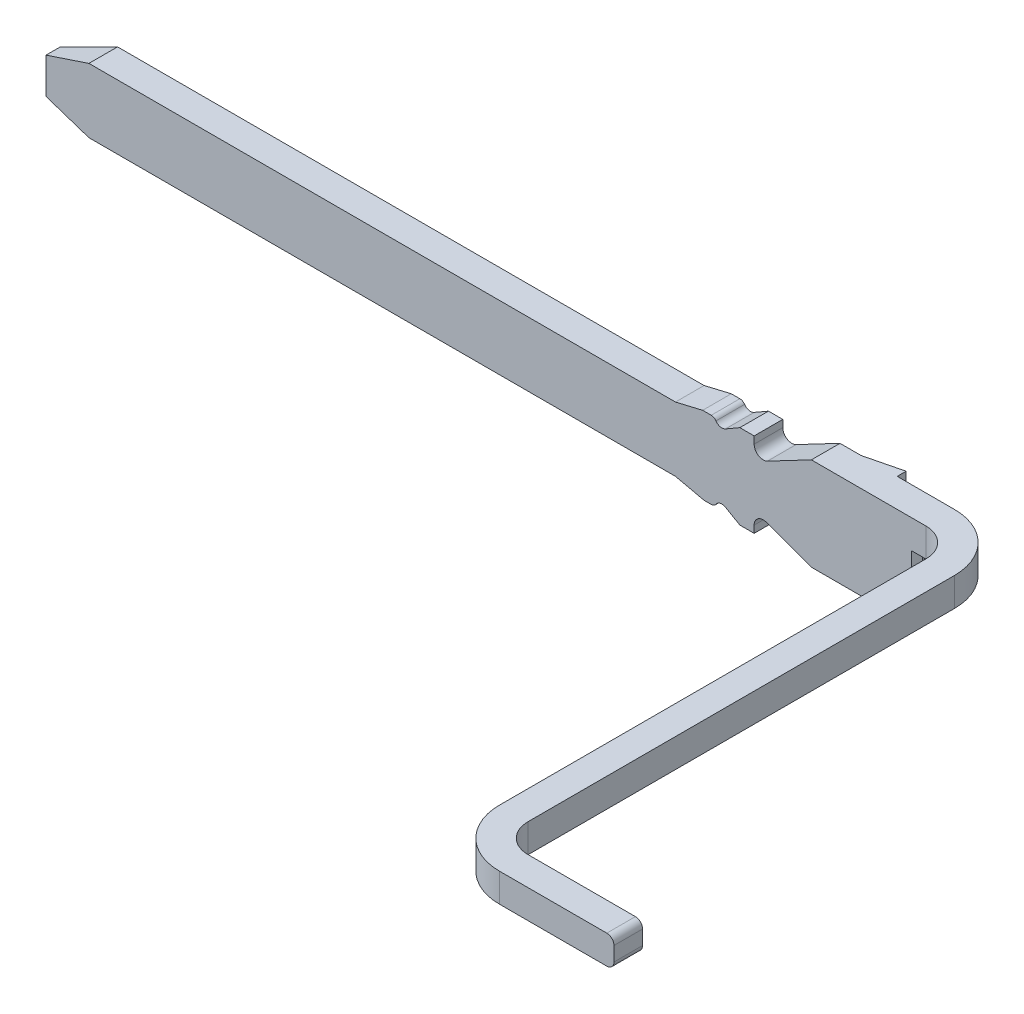
from build123d import *

# Parameters (mm, degrees)
RESSALTO_EXTRUS_O1_DEPTH = 0.2
RESSALTO_EXTRUS_O2_DEPTH = 0.2
CORTE_EXTRUS_O1_DEPTH    = 1
FILETE1_R                = 0.05
RESSALTO_EXTRUS_O3_DEPTH = 0.145
PADR_O_LINEAR1_COUNT     = 2
PADR_O_LINEAR1_PITCH     = 0.505
CORTE_EXTRUS_O2_DEPTH    = 0.3


with BuildPart() as part:
    # Esboço1 → Ressalto-extrusão1 (new body)
    with BuildSketch(Plane.XY):
        with BuildLine():
            Line((76.710328142, 206.616112347), (76.710328142, 206.416112347))
            Line((76.710328142, 206.416112347), (76.657349848, 206.416112347))
            Line((76.657349848, 206.416112347), (76.657349848, 206.116112347))
            Line((76.657349848, 206.116112347), (76.645328142, 206.116112347))
            Line((76.645328142, 206.116112347), (76.610328142, 206.116112347))
            Line((76.610328142, 206.116112347), (76.560328142, 206.116112347))
            ThreePointArc((76.560328142, 206.116112347), (76.524972803, 206.101467686), (76.510328142, 206.066112347))
            Line((76.510328142, 206.066112347), (76.510328142, 205.966112347))
            Line((76.510328142, 205.966112347), (76.110328142, 205.966112347))
            Line((76.110328142, 205.966112347), (76.081970009, 205.966112347))
            Line((76.081970009, 205.966112347), (75.910328142, 205.966112347))
            Line((75.910328142, 205.966112347), (75.595453106, 206.080717488))
            ThreePointArc((75.595453106, 206.080717488), (75.537376388, 206.073071543), (75.510328142, 206.021112347))
            Line((75.510328142, 206.021112347), (75.510328142, 205.971112347))
            Line((75.510328142, 205.971112347), (75.410328142, 205.971112347))
            Line((75.410328142, 205.971112347), (75.309933917, 206.02907498))
            ThreePointArc((75.309933917, 206.02907498), (75.273690046, 206.034493063), (75.243486264, 206.013739619))
            ThreePointArc((75.243486264, 206.013739619), (75.229104336, 206.000793024), (75.210328142, 205.996112347))
            Line((75.210328142, 205.996112347), (75.160328142, 205.996112347))
            Line((75.160328142, 205.996112347), (74.960328142, 206.041112347))
            Line((74.960328142, 206.041112347), (70.860328142, 206.041112347))
            Line((70.860328142, 206.041112347), (70.560328142, 206.141112347))
            Line((70.560328142, 206.141112347), (70.560328142, 206.391112347))
            Line((70.560328142, 206.391112347), (70.860328142, 206.491112347))
            Line((70.860328142, 206.491112347), (74.960328142, 206.491112347))
            Line((74.960328142, 206.491112347), (75.150344741, 206.536112347))
            Line((75.150344741, 206.536112347), (75.210328142, 206.536112347))
            ThreePointArc((75.210328142, 206.536112347), (75.229104336, 206.53143167), (75.243486264, 206.518485075))
            ThreePointArc((75.243486264, 206.518485075), (75.273690046, 206.497731631), (75.309933917, 206.503149714))
            Line((75.309933917, 206.503149714), (75.410328142, 206.561112347))
            Line((75.410328142, 206.561112347), (75.510328142, 206.561112347))
            Line((75.510328142, 206.561112347), (75.510328142, 206.511112347))
            ThreePointArc((75.510328142, 206.511112347), (75.540942979, 206.456830135), (75.60323487, 206.454946752))
            Line((75.60323487, 206.454946752), (75.910328142, 206.616112347))
            Line((75.910328142, 206.616112347), (76.081970009, 206.616112347))
            Line((76.081970009, 206.616112347), (76.110328142, 206.616112347))
            Line((76.110328142, 206.616112347), (76.710328142, 206.616112347))
        make_face()
    extrude(amount=RESSALTO_EXTRUS_O1_DEPTH)

    # Esboço2 → Ressalto-extrusão2 (add)
    with BuildSketch(Plane.XZ.offset(-206.416112347)):
        with BuildLine():
            Line((76.710328142, 0), (76.710328142, 0.2))
            ThreePointArc((76.710328142, 0.2), (76.851749499, 0.258578644), (76.910328142, 0.4))
            Line((76.910328142, 0.4), (76.910328142, 3.38))
            ThreePointArc((76.910328142, 3.38), (77.02748543, 3.662842712), (77.310328142, 3.78))
            Line((77.310328142, 3.78), (78.110328142, 3.78))
            Line((78.110328142, 3.78), (78.110328142, 3.58))
            Line((78.110328142, 3.58), (77.310328142, 3.58))
            ThreePointArc((77.310328142, 3.58), (77.168906786, 3.521421356), (77.110328142, 3.38))
            Line((77.110328142, 3.38), (77.110328142, 0.4))
            ThreePointArc((77.110328142, 0.4), (76.993170855, 0.117157288), (76.710328142, 0))
        make_face()
    extrude(amount=-RESSALTO_EXTRUS_O2_DEPTH)

    # Esboço3 → Corte-extrusão1 (cut)
    with BuildSketch(Plane(origin=(0, 206.491112347, 0), x_dir=(1, 0, 0), z_dir=(0, 1, 0))):
        Polygon((70.860328142, 0), (70.560328142, -0.1), (70.475949981, -0.1), (70.475949981, 0.09851766), (70.860328142, 0.09851766), align=None)
    extrude(amount=-CORTE_EXTRUS_O1_DEPTH, mode=Mode.SUBTRACT)

    # Filete1
    filete1_edges = [part.edges().sort_by_distance(p)[0] for p in [
        (78.110328142, 206.616112347, 3.68),
        (78.110328142, 206.416112347, 3.68),
    ]]
    fillet(filete1_edges, radius=FILETE1_R)

    # Esboço4 → Ressalto-extrusão3 (add)
    with BuildSketch(Plane(origin=(0, 206.616112347, 0), x_dir=(1, 0, 0), z_dir=(0, 1, 0))):
        Polygon((76.057628142, 0), (76.310328142, 0), (76.310328142, 0.0624), align=None)
    ressalto_extrus_o3 = extrude(amount=-RESSALTO_EXTRUS_O3_DEPTH)

    # Padrão linear1: Ressalto-extrusão3 ×2
    with Locations(*[(0, -i * PADR_O_LINEAR1_PITCH, 0) for i in range(1, PADR_O_LINEAR1_COUNT)]):
        add(ressalto_extrus_o3)

    # Esboço5 → Corte-extrusão2 (cut)
    with BuildSketch(Plane.XZ.offset(-206.116112347)):
        Polygon((76.657349848, 0.16), (76.645349848, 0.16), (76.608838995, 0.2), (76.608838995, 0.232444762), (76.679680574, 0.232444762), (76.679680574, 0.16), align=None)
        Polygon((76.608838995, 0), (76.645349848, 0.04), (76.679680574, 0.04), (76.679680574, -0.014078239), (76.608838995, -0.014078239), align=None)
    extrude(amount=-CORTE_EXTRUS_O2_DEPTH, mode=Mode.SUBTRACT)


solid = part.part
